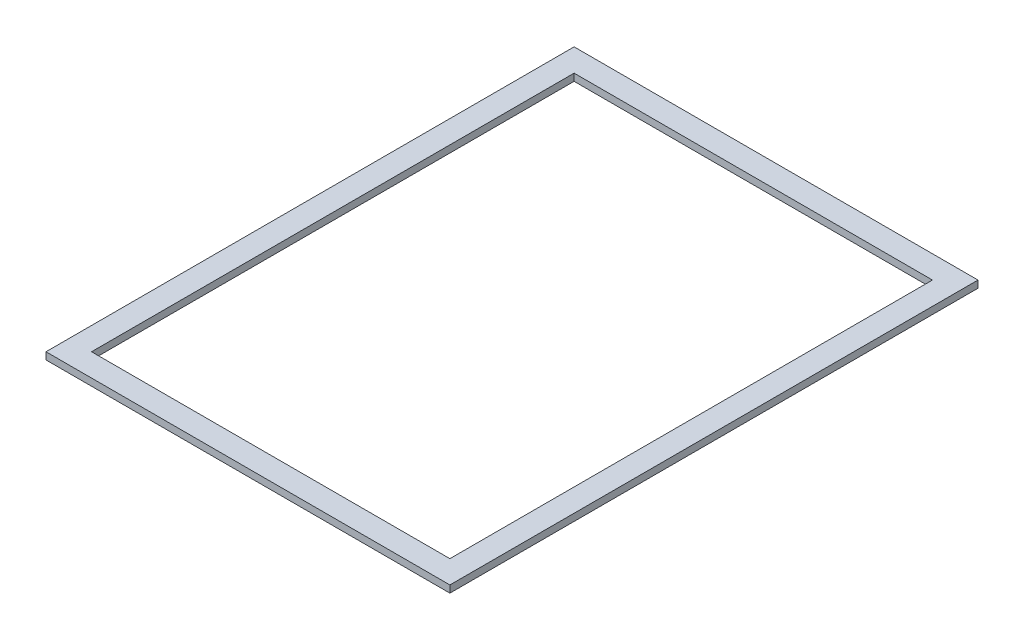
from build123d import *

# Parameters (mm, degrees)
SKETCH1_W           = 90.114
SKETCH1_H           = 117.828
SKETCH1_W_2         = 79.954
SKETCH1_H_2         = 107.668
BOSS_EXTRUDE1_DEPTH = 1.5875


with BuildPart() as part:
    # Sketch1 → Boss-Extrude1 (new body)
    with BuildSketch(Plane(origin=(0, 129.032, 0), x_dir=(1, 0, 0), z_dir=(0, 1, 0))):
        with Locations((45.057, 58.914)):
            Rectangle(SKETCH1_W, SKETCH1_H)
        with Locations((45.057, 58.914)):
            Rectangle(SKETCH1_W_2, SKETCH1_H_2, mode=Mode.SUBTRACT)
    extrude(amount=BOSS_EXTRUDE1_DEPTH)


solid = part.part
